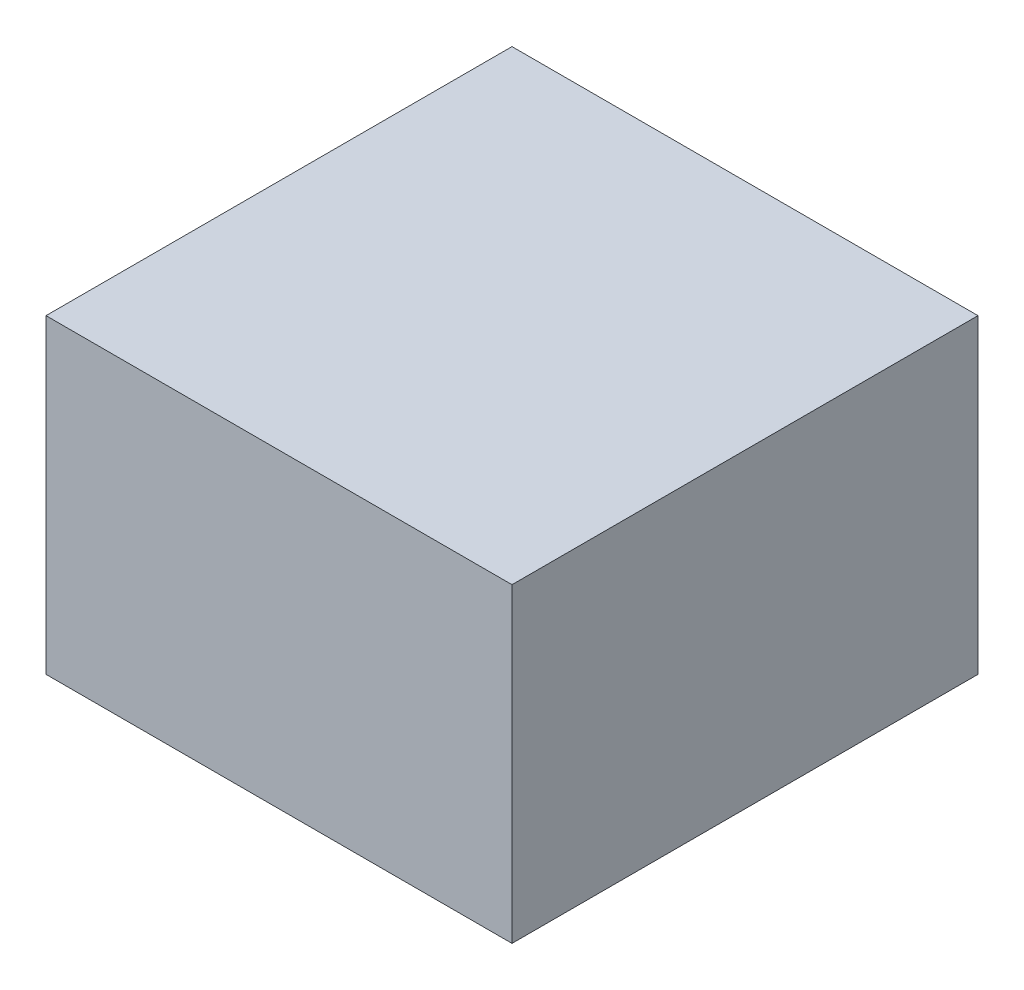
from build123d import *

# Parameters (mm, degrees)
CROQUIS1_W              = 30
CROQUIS1_H              = 30
SALIENTE_EXTRUIR1_DEPTH = 20


with BuildPart() as part:
    # Croquis1 → Saliente-Extruir1 (new body)
    with BuildSketch(Plane(origin=(0, 0, 0), x_dir=(1, 0, 0), z_dir=(0, 1, 0))):
        Rectangle(CROQUIS1_W, CROQUIS1_H)
    extrude(amount=SALIENTE_EXTRUIR1_DEPTH)


solid = part.part
